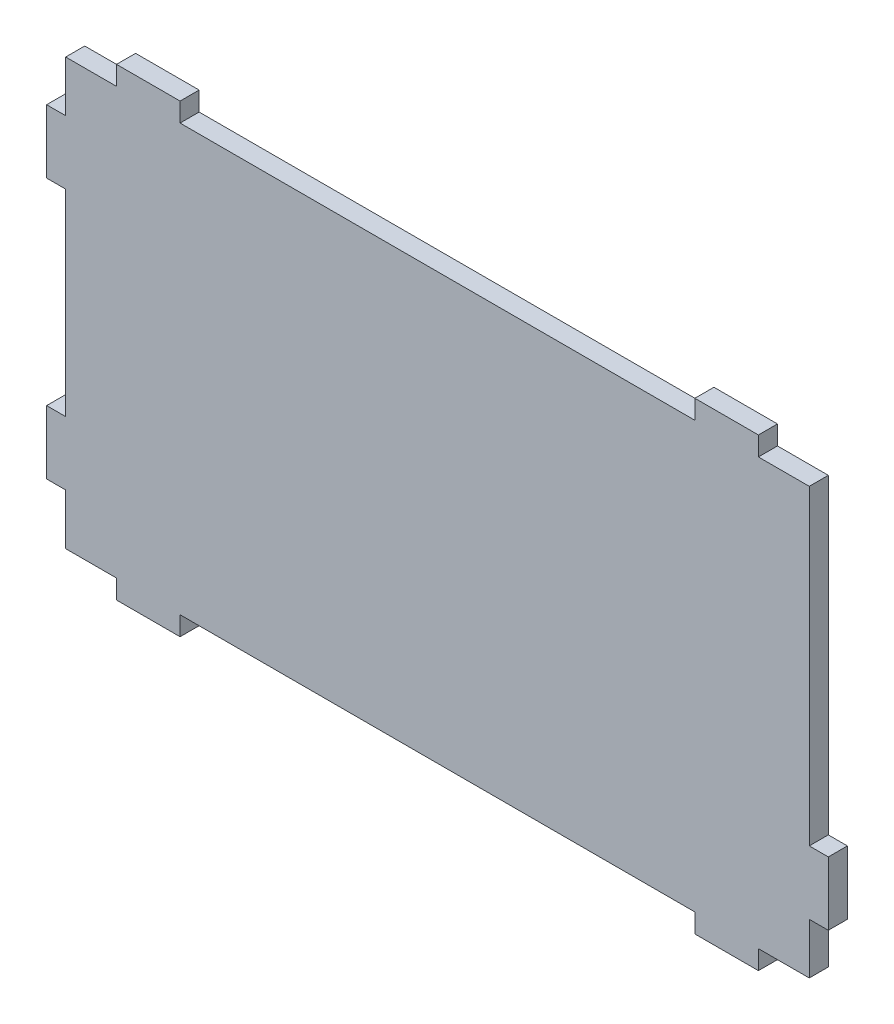
from build123d import *

# Parameters (mm, degrees)
SALIENTE_EXTRUIR1_DEPTH = 3


with BuildPart() as part:
    # Croquis1 → Saliente-Extruir1 (new body)
    with BuildSketch(Plane.XY):
        Polygon((65.124760077, 33.623800384), (57.124760077, 33.623800384), (57.124760077, 36.623800384), (47.124760077, 36.623800384), (47.124760077, 33.623800384), (-33.875239923, 33.623800384), (-33.875239923, 36.623800384), (-43.875239923, 36.623800384), (-43.875239923, 33.623800384), (-51.875239923, 33.623800384), (-51.875239923, 25.623800384), (-54.875239923, 25.623800384), (-54.875239923, 15.623800384), (-51.875239923, 15.623800384), (-51.875239923, -15.376199616), (-54.875239923, -15.376199616), (-54.875239923, -25.376199616), (-51.875239923, -25.376199616), (-51.875239923, -33.376199616), (-43.875239923, -33.376199616), (-43.875239923, -36.376199616), (-33.875239923, -36.376199616), (-33.875239923, -33.376199616), (47.124760077, -33.376199616), (47.124760077, -36.376199616), (57.124760077, -36.376199616), (57.124760077, -33.376199616), (65.124760077, -33.376199616), (65.124760077, -25.376199616), (68.124760077, -25.376199616), (68.124760077, -15.376199616), (65.124760077, -15.376199616), align=None)
    extrude(amount=SALIENTE_EXTRUIR1_DEPTH)


solid = part.part
